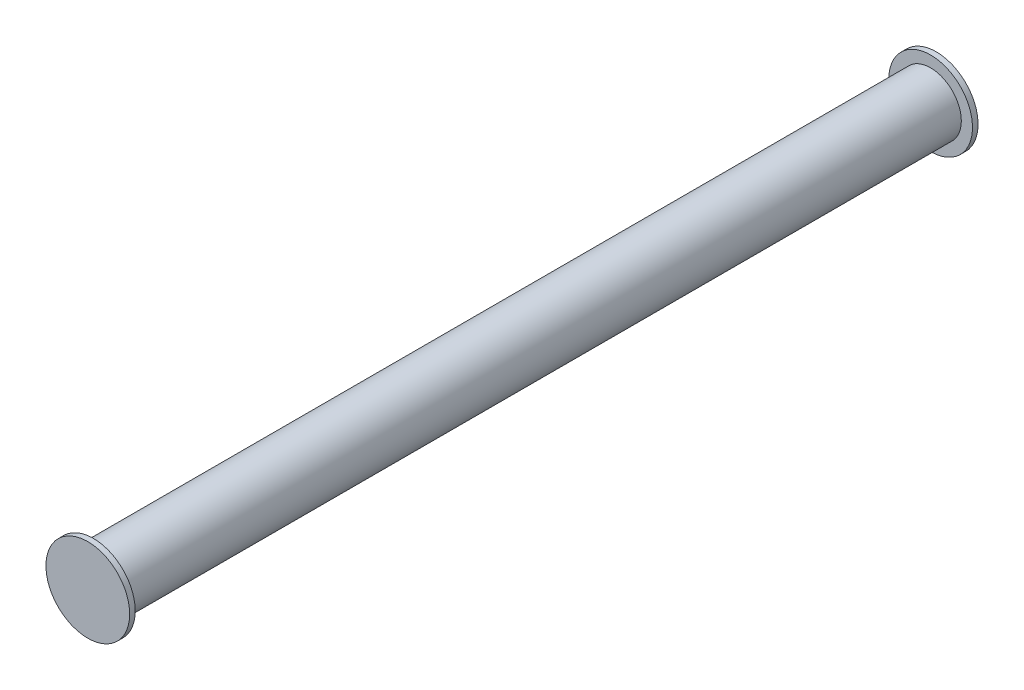
from build123d import *

# Parameters (mm, degrees)
SKETCH1_R           = 5.5
BOSS_EXTRUDE1_DEPTH = 150
SKETCH2_R           = 7.5
BOSS_EXTRUDE2_DEPTH = 1
SKETCH3_R           = 7.5
BOSS_EXTRUDE3_DEPTH = 1


with BuildPart() as part:
    # Sketch1 → Boss-Extrude1 (new body)
    with BuildSketch(Plane.XY):
        Circle(SKETCH1_R)
    extrude(amount=BOSS_EXTRUDE1_DEPTH)

    # Sketch2 → Boss-Extrude2 (add)
    with BuildSketch(Plane(origin=(0, 0, 0), x_dir=(-1, 0, 0), z_dir=(0, 0, -1))):
        Circle(SKETCH2_R)
    extrude(amount=BOSS_EXTRUDE2_DEPTH)

    # Sketch3 → Boss-Extrude3 (add)
    with BuildSketch(Plane.XY.offset(150)):
        Circle(SKETCH3_R)
    extrude(amount=BOSS_EXTRUDE3_DEPTH)


solid = part.part
